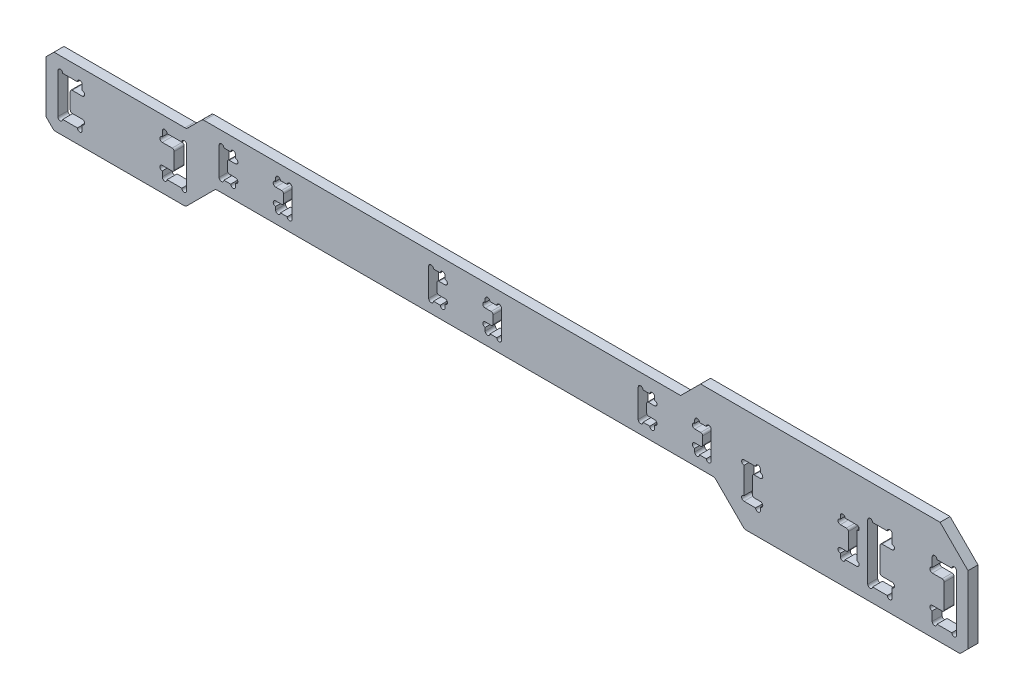
from build123d import *

# Parameters (mm, degrees)
SKETCH_1_W                     = 231
SKETCH_1_H                     = 17
EXTRUDE_1_DEPTH                = 1.25
SKETCH_2_R                     = 0.6
CUT_EXTRUDE_1_DEPTH            = 3.5
FILLET_1_R                     = 0.5
CHAMFER_1_SIZE                 = 2
CUT_EXTRUDE_2_DEPTH            = 3.5
EXTRUDE_2_DEPTH                = 2.5
CUT_EXTRUDE_START              = -3.5
CUT_EXTRUDE_3_DEPTH            = 4.5
SKETCH_6_R                     = 0.6
CUT_EXTRUDE_4_DEPTH            = 3.5
FILLET_2_R                     = 0.5
PATTERN_LINEAR_1_COUNT         = 3
PATTERN_LINEAR_1_PITCH         = 52.5
FILLET_2_OF_PATTERN_LINEAR_1_R = 0.5
CUT_EXTRUDE_5_DEPTH            = 3.5
SKETCH_8_R                     = 0.6
CUT_EXTRUDE_6_DEPTH            = 3.5
FILLET_3_R                     = 0.5
FILLET_4_R                     = 1
CHAMFER_2_SIZE                 = 2
EXTRUDE_3_DEPTH                = 2.5
CUT_EXTRUDE_7_DEPTH            = 3.5
SKETCH_11_R                    = 0.6
CUT_EXTRUDE_8_DEPTH            = 3.5
FILLET_5_R                     = 0.5


with BuildPart() as part:
    # 草图1 → 凸台-拉伸1 (new body, symmetric)
    with BuildSketch(Plane.XY):
        Rectangle(SKETCH_1_W, SKETCH_1_H)
        Polygon((-106.425, 2.5), (-109.425, 2.5), (-109.425, -2.5), (-106.425, -2.5), (-106.425, -5), (-112.525, -5), (-112.525, 5), (-106.425, 5), align=None, mode=Mode.SUBTRACT)
        Polygon((-80.275, -5), (-86.375, -5), (-86.375, -2.5), (-83.375, -2.5), (-83.375, 2.5), (-86.375, 2.5), (-86.375, 5), (-80.275, 5), align=None, mode=Mode.SUBTRACT)
    extrude(amount=EXTRUDE_1_DEPTH, both=True)

    # 草图2 → 切除-拉伸1 (cut, through all)
    with BuildSketch(Plane.XY.offset(1.25)):
        with Locations((-106.425, 3.1)):
            Circle(SKETCH_2_R)
        with Locations((-106.425, -3.1)):
            Circle(SKETCH_2_R)
        with Locations((-107.025, 5)):
            Circle(SKETCH_2_R)
        with Locations((-107.025, -5)):
            Circle(SKETCH_2_R)
        with Locations((-111.925, -5)):
            Circle(SKETCH_2_R)
        with Locations((-111.925, 5)):
            Circle(SKETCH_2_R)
        with Locations((-86.375, 3.1)):
            Circle(SKETCH_2_R)
        with Locations((-86.375, -3.1)):
            Circle(SKETCH_2_R)
        with Locations((-85.775, 5)):
            Circle(SKETCH_2_R)
        with Locations((-80.875, 5)):
            Circle(SKETCH_2_R)
        with Locations((-85.775, -5)):
            Circle(SKETCH_2_R)
        with Locations((-80.875, -5)):
            Circle(SKETCH_2_R)
    extrude(amount=-CUT_EXTRUDE_1_DEPTH, mode=Mode.SUBTRACT)

    # 圆角1
    fillet_1_edges = [part.edges().sort_by_distance(p)[0] for p in [
        (-109.425, -2.5, 0),
        (-109.425, 2.5, 0),
        (-83.375, 2.5, 0),
        (-83.375, -2.5, 0),
    ]]
    fillet(fillet_1_edges, radius=FILLET_1_R)

    # 倒角1
    chamfer_1_edges = [part.edges().sort_by_distance(p)[0] for p in [
        (-115.5, 8.5, 0),
        (-115.5, -8.5, 0),
    ]]
    chamfer(chamfer_1_edges, length=CHAMFER_1_SIZE)

    # 草图3 → 切除-拉伸2 (cut, through all)
    with BuildSketch(Plane.XY.offset(1.25)):
        Polygon((-73, -1), (52, -1), (59.5, -8.5), (-80.5, -8.5), align=None)
    extrude(amount=-CUT_EXTRUDE_2_DEPTH, mode=Mode.SUBTRACT)

    # 草图4 → 凸台-拉伸2 (add)
    with BuildSketch(Plane.XY.offset(1.25)):
        Polygon((-80.275, 8.5), (-76.275, 12.5), (115.5, 12.5), (115.5, 8.5), align=None)
    extrude(amount=-EXTRUDE_2_DEPTH)

    # 草图5 → 切除-拉伸3 (cut)
    with BuildSketch(Plane.XY.offset(1.25).offset(CUT_EXTRUDE_START)):
        Polygon((-68.025, 9), (-72.125, 9), (-72.125, 2), (-68.025, 2), (-68.025, 4), (-70.025, 4), (-70.025, 7), (-68.025, 7), align=None)
        Polygon((-57.975, 9), (-57.975, 7), (-55.975, 7), (-55.975, 4), (-57.975, 4), (-57.975, 2), (-53.875, 2), (-53.875, 9), align=None)
    cut_extrude_3 = extrude(amount=CUT_EXTRUDE_3_DEPTH, mode=Mode.SUBTRACT)

    # 草图6 → 切除-拉伸4 (cut, through all)
    with BuildSketch(Plane.XY.offset(1.25)):
        with Locations((-68.025, 7.6)):
            Circle(SKETCH_6_R)
        with Locations((-68.625, 9)):
            Circle(SKETCH_6_R)
        with Locations((-71.525, 9)):
            Circle(SKETCH_6_R)
        with Locations((-71.525, 2)):
            Circle(SKETCH_6_R)
        with Locations((-68.025, 3.4)):
            Circle(SKETCH_6_R)
        with Locations((-68.625, 2)):
            Circle(SKETCH_6_R)
        with Locations((-57.975, 3.4)):
            Circle(SKETCH_6_R)
        with Locations((-57.975, 7.6)):
            Circle(SKETCH_6_R)
        with Locations((-57.375, 9)):
            Circle(SKETCH_6_R)
        with Locations((-57.375, 2)):
            Circle(SKETCH_6_R)
        with Locations((-54.475, 2)):
            Circle(SKETCH_6_R)
        with Locations((-54.475, 9)):
            Circle(SKETCH_6_R)
    cut_extrude_4 = extrude(amount=-CUT_EXTRUDE_4_DEPTH, mode=Mode.SUBTRACT)

    # 圆角2
    fillet_2_edges = [part.edges().sort_by_distance(p)[0] for p in [
        (-70.025, 7, 0),
        (-70.025, 4, 0),
        (-55.975, 7, 0),
        (-55.975, 4, 0),
    ]]
    fillet(fillet_2_edges, radius=FILLET_2_R)

    # 阵列(线性)1: 切除-拉伸3, 切除-拉伸4 ×3
    with Locations(*[(i * PATTERN_LINEAR_1_PITCH, 0, 0) for i in range(1, PATTERN_LINEAR_1_COUNT)]):
        add(cut_extrude_3, mode=Mode.SUBTRACT)
        add(cut_extrude_4, mode=Mode.SUBTRACT)

    # 圆角2 of 阵列(线性)1
    fillet_2_of_pattern_linear_1_edges = [part.edges().sort_by_distance(p)[0] for p in [
        (-17.525, 7, 0),
        (-17.525, 4, 0),
        (-3.475, 7, 0),
        (-3.475, 4, 0),
        (34.975, 7, 0),
        (34.975, 4, 0),
        (49.025, 7, 0),
        (49.025, 4, 0),
    ]]
    fillet(fillet_2_of_pattern_linear_1_edges, radius=FILLET_2_OF_PATTERN_LINEAR_1_R)

    # 草图7 → 切除-拉伸5 (cut, through all)
    with BuildSketch(Plane.XY.offset(1.25)):
        Polygon((106.525, 9), (112.625, 9), (112.625, -5), (106.525, -5), (106.525, -1.5), (109.525, -1.5), (109.525, 5.5), (106.525, 5.5), align=None)
        Polygon((96.475, 5.5), (96.475, 9), (90.375, 9), (90.375, -5), (96.475, -5), (96.475, -1.5), (93.475, -1.5), (93.475, 5.5), align=None)
    extrude(amount=-CUT_EXTRUDE_5_DEPTH, mode=Mode.SUBTRACT)

    # 草图8 → 切除-拉伸6 (cut, through all)
    with BuildSketch(Plane.XY.offset(1.25)):
        with Locations((90.975, 9)):
            Circle(SKETCH_8_R)
        with Locations((95.875, 9)):
            Circle(SKETCH_8_R)
        with Locations((96.475, 6.1)):
            Circle(SKETCH_8_R)
        with Locations((96.475, -2.1)):
            Circle(SKETCH_8_R)
        with Locations((95.875, -5)):
            Circle(SKETCH_8_R)
        with Locations((90.975, -5)):
            Circle(SKETCH_8_R)
        with Locations((106.525, 6.1)):
            Circle(SKETCH_8_R)
        with Locations((106.525, -2.1)):
            Circle(SKETCH_8_R)
        with Locations((107.125, 9)):
            Circle(SKETCH_8_R)
        with Locations((112.025, 9)):
            Circle(SKETCH_8_R)
        with Locations((112.025, -5)):
            Circle(SKETCH_8_R)
        with Locations((107.125, -5)):
            Circle(SKETCH_8_R)
    extrude(amount=-CUT_EXTRUDE_6_DEPTH, mode=Mode.SUBTRACT)

    # 圆角3
    fillet_3_edges = [part.edges().sort_by_distance(p)[0] for p in [
        (109.525, -1.5, 0),
        (109.525, 5.5, 0),
        (93.475, 5.5, 0),
        (93.475, -1.5, 0),
    ]]
    fillet(fillet_3_edges, radius=FILLET_3_R)

    # 圆角4
    fillet_4_edges = [part.edges().sort_by_distance(p)[0] for p in [
        (-80.5, -8.5, 0),
        (-73, -1, 0),
        (52, -1, 0),
        (59.5, -8.5, 0),
        (-80.275, 8.5, 0),
        (-76.275, 12.5, 0),
    ]]
    fillet(fillet_4_edges, radius=FILLET_4_R)

    # 倒角2
    chamfer_2_edges = [part.edges().sort_by_distance(p)[0] for p in [
        (115.5, 12.5, 0),
        (115.5, -8.5, 0),
    ]]
    chamfer(chamfer_2_edges, length=CHAMFER_2_SIZE)

    # 草图9 → 凸台-拉伸3 (add)
    with BuildSketch(Plane.XY.offset(1.25)):
        Polygon((113.5, 12.5), (108.5, 17.5), (48.5, 17.5), (43.5, 12.5), align=None)
    extrude(amount=-EXTRUDE_3_DEPTH)

    # 草图10 → 切除-拉伸7 (cut, through all)
    with BuildSketch(Plane.XY.offset(1.25)):
        Polygon((59.375, 6.5), (63.475, 6.5), (63.475, 4.5), (61.475, 4.5), (61.475, -0.5), (63.475, -0.5), (63.475, -2.5), (59.375, -2.5), align=None)
        Polygon((83.525, 6.5), (83.525, 4.5), (85.525, 4.5), (85.525, -0.5), (83.525, -0.5), (83.525, -2.5), (87.625, -2.5), (87.625, 6.5), align=None)
    extrude(amount=-CUT_EXTRUDE_7_DEPTH, mode=Mode.SUBTRACT)

    # 草图11 → 切除-拉伸8 (cut, through all)
    with BuildSketch(Plane.XY.offset(1.25)):
        with Locations((63.475, 5.1)):
            Circle(SKETCH_11_R)
        with Locations((62.875, 6.5)):
            Circle(SKETCH_11_R)
        with Locations((59.375, 5.9)):
            Circle(SKETCH_11_R)
        with Locations((59.375, -1.9)):
            Circle(SKETCH_11_R)
        with Locations((63.475, -1.1)):
            Circle(SKETCH_11_R)
        with Locations((62.875, -2.5)):
            Circle(SKETCH_11_R)
        with Locations((83.525, -1.1)):
            Circle(SKETCH_11_R)
        with Locations((84.125, -2.5)):
            Circle(SKETCH_11_R)
        with Locations((87.625, -1.9)):
            Circle(SKETCH_11_R)
        with Locations((87.625, 5.9)):
            Circle(SKETCH_11_R)
        with Locations((83.525, 5.1)):
            Circle(SKETCH_11_R)
        with Locations((84.125, 6.5)):
            Circle(SKETCH_11_R)
    extrude(amount=-CUT_EXTRUDE_8_DEPTH, mode=Mode.SUBTRACT)

    # 圆角5
    fillet_5_edges = [part.edges().sort_by_distance(p)[0] for p in [
        (61.475, 4.5, 0),
        (61.475, -0.5, 0),
        (85.525, -0.5, 0),
        (85.525, 4.5, 0),
    ]]
    fillet(fillet_5_edges, radius=FILLET_5_R)


solid = part.part
